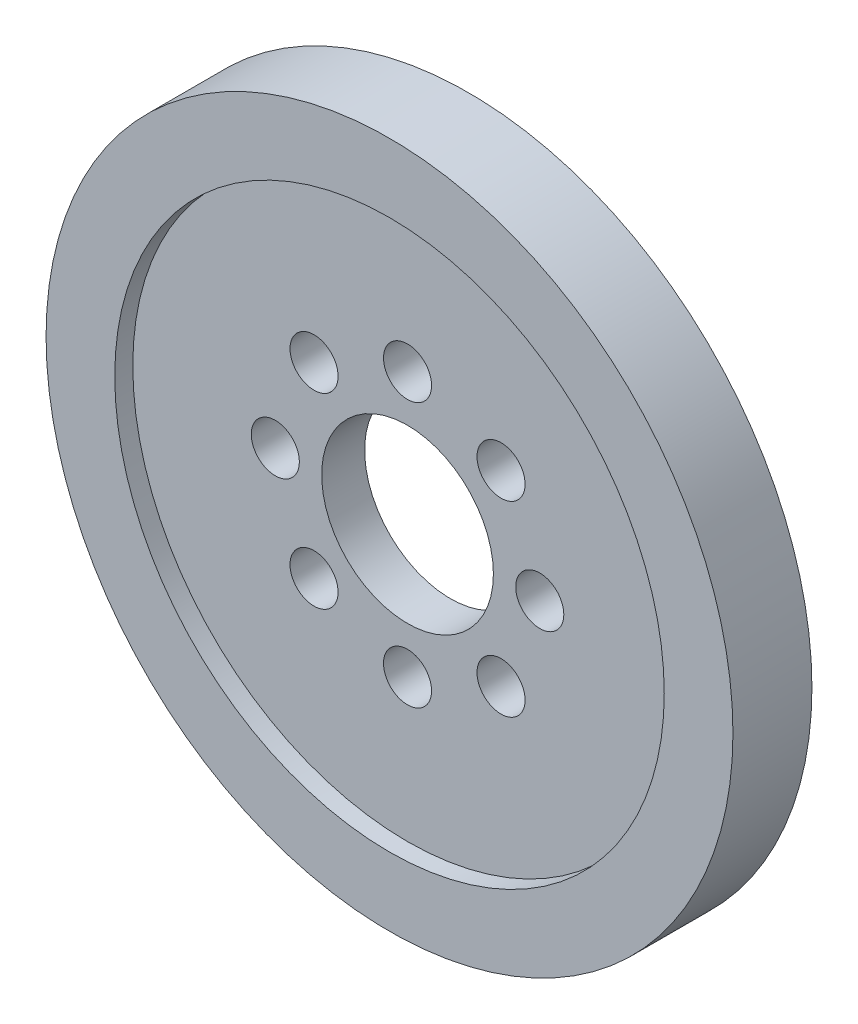
from build123d import *

# Parameters (mm, degrees)
SKETCH1_R           = 25.4
SKETCH1_R_2         = 20.32
BOSS_EXTRUDE1_DEPTH = 2.921
SKETCH3_R           = 20.32
SKETCH3_R_2         = 6.35
SKETCH3_R_3         = 1.778
BOSS_EXTRUDE2_DEPTH = 1.5875


with BuildPart() as part:
    # Sketch1 → Boss-Extrude1 (new body, symmetric)
    with BuildSketch(Plane.XY):
        Circle(SKETCH1_R)
        Circle(SKETCH1_R_2, mode=Mode.SUBTRACT)
    extrude(amount=BOSS_EXTRUDE1_DEPTH, both=True)

    # Sketch3 → Boss-Extrude2 (add, symmetric)
    with BuildSketch(Plane.XY):
        Circle(SKETCH3_R)
        Circle(SKETCH3_R_2, mode=Mode.SUBTRACT)
        with Locations((0, 9.779)):
            Circle(SKETCH3_R_3, mode=Mode.SUBTRACT)
        with Locations((6.914797213, 6.914797213)):
            Circle(SKETCH3_R_3, mode=Mode.SUBTRACT)
        with Locations((9.779, 0)):
            Circle(SKETCH3_R_3, mode=Mode.SUBTRACT)
        with Locations((6.914797213, -6.914797213)):
            Circle(SKETCH3_R_3, mode=Mode.SUBTRACT)
        with Locations((0, -9.779)):
            Circle(SKETCH3_R_3, mode=Mode.SUBTRACT)
        with Locations((-6.914797213, -6.914797213)):
            Circle(SKETCH3_R_3, mode=Mode.SUBTRACT)
        with Locations((-9.779, 0)):
            Circle(SKETCH3_R_3, mode=Mode.SUBTRACT)
        with Locations((-6.914797213, 6.914797213)):
            Circle(SKETCH3_R_3, mode=Mode.SUBTRACT)
    extrude(amount=BOSS_EXTRUDE2_DEPTH, both=True)


solid = part.part
